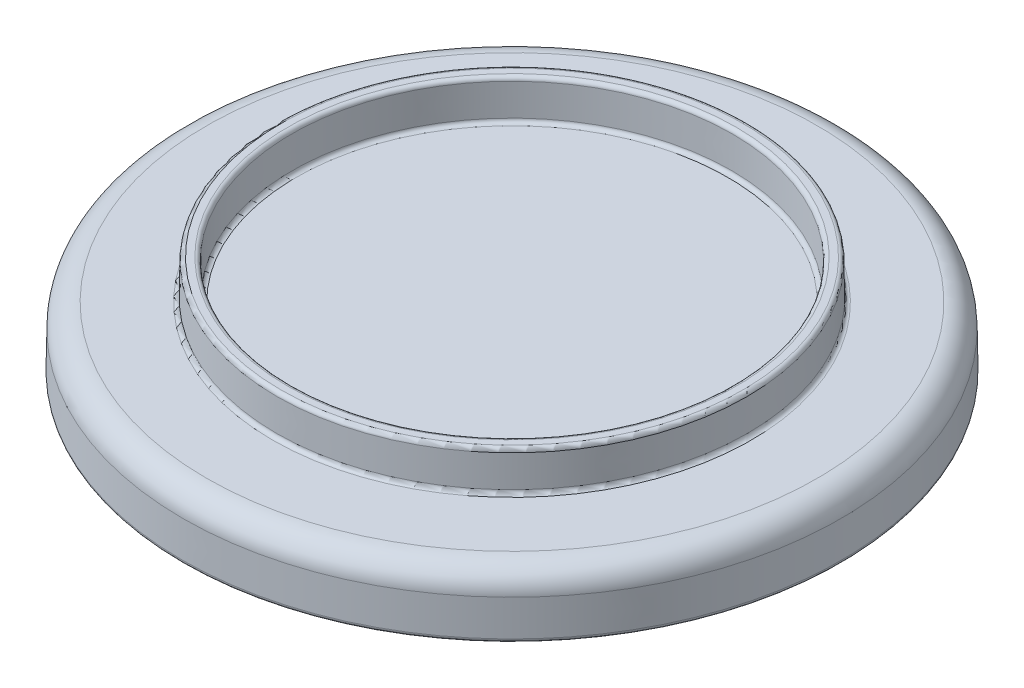
from build123d import *

# Parameters (mm, degrees)
SKETCH1_R           = 40
BOSS_EXTRUDE1_DEPTH = 6
BOSS_EXTRUDE1_TAPER = 1
SHELL1_T            = 2
SKETCH2_R           = 30
SKETCH2_R_2         = 28
BOSS_EXTRUDE2_DEPTH = 5
BOSS_EXTRUDE2_DRAFT = 1
FILLET1_R           = 0.5
FILLET2_R           = 1
FILLET3_R           = 3
FILLET4_R           = 0.5


with BuildPart() as part:
    # Sketch1 → Boss-Extrude1 (new body)
    with BuildSketch(Plane(origin=(0, 0, 0), x_dir=(1, 0, 0), z_dir=(0, 1, 0))):
        Circle(SKETCH1_R)
    extrude(amount=BOSS_EXTRUDE1_DEPTH, taper=BOSS_EXTRUDE1_TAPER)

    # Shell1
    shell1_openings = [part.faces().sort_by_distance(p)[0] for p in [
        (0, 0, 0),
    ]]
    offset(amount=SHELL1_T, openings=shell1_openings, kind=Kind.INTERSECTION)


with BuildPart() as boss_extrude2_tool:
    # Sketch2 → Boss-Extrude2 (with draft: the straight prism first)
    with BuildSketch(Plane(origin=(0, 8, 0), x_dir=(1, 0, 0), z_dir=(0, 1, 0))):
        Circle(SKETCH2_R)
        Circle(SKETCH2_R_2, mode=Mode.SUBTRACT)
    extrude(amount=BOSS_EXTRUDE2_DEPTH)
    # Boss-Extrude2: the draft: its side faces are tilted about the plane it starts from
    boss_extrude2_sides = [boss_extrude2_tool.faces().sort_by_distance(p)[0] for p in [
        (-30, 10.5, 0),
        (-28, 10.5, 0),
    ]]
    draft(boss_extrude2_sides, Plane(origin=(0, 8, 0), x_dir=(1, 0, 0), z_dir=(0, 1, 0)), BOSS_EXTRUDE2_DRAFT)


with BuildPart() as part_1:
    add(part.part)

    # Boss-Extrude2: add boss_extrude2_tool
    add(boss_extrude2_tool.part)

    # Fillet1
    fillet1_edges = [part_1.edges().sort_by_distance(p)[0] for p in [
        (-29.912724675, 13, 0),
        (-28.087275325, 13, 0),
        (-42.000304656, 0, 0),
        (-40, 0, 0),
    ]]
    fillet(fillet1_edges, radius=FILLET1_R)

    # Fillet2
    fillet2_edges = [part_1.edges().sort_by_distance(p)[0] for p in [
        (-39.89526961, 6, 0),
    ]]
    fillet(fillet2_edges, radius=FILLET2_R)

    # Fillet3
    fillet3_edges = [part_1.edges().sort_by_distance(p)[0] for p in [
        (-41.860664137, 8, 0),
    ]]
    fillet(fillet3_edges, radius=FILLET3_R)

    # Fillet4
    fillet4_edges = [part_1.edges().sort_by_distance(p)[0] for p in [
        (-30, 8, 0),
        (-28, 8, 0),
    ]]
    fillet(fillet4_edges, radius=FILLET4_R)


solid = part_1.part
